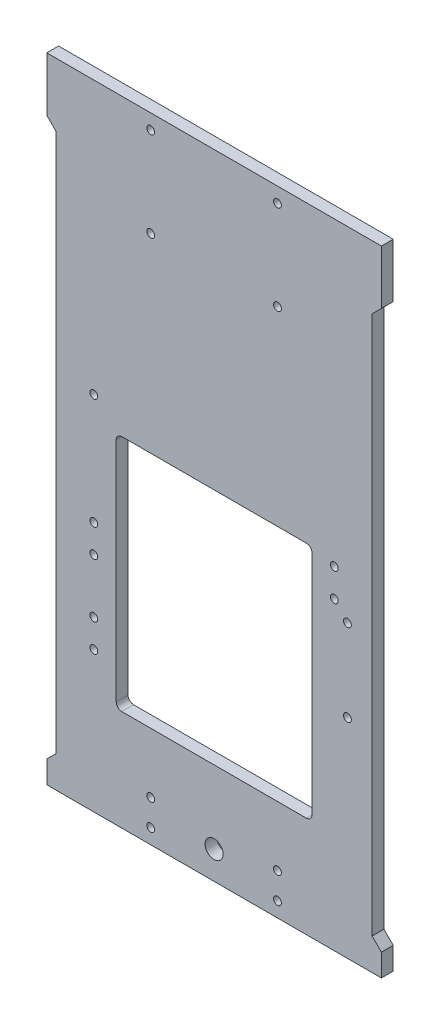
from build123d import *

# Parameters (mm, degrees)
BOSS_EXTRUDE1_DEPTH = 6.35
CUT_EXTRUDE1_DEPTH  = 7.35
SKETCH3_R           = 2.1
CUT_EXTRUDE2_DEPTH  = 7.35
SKETCH4_R           = 2.1
CUT_EXTRUDE3_DEPTH  = 7.35
SKETCH5_R           = 4.85
CUT_EXTRUDE4_DEPTH  = 7.35


with BuildPart() as part:
    # Sketch1 → Boss-Extrude1 (new body)
    with BuildSketch(Plane.XY):
        Polygon((-89.75, 0), (89.75, 0), (89.75, 12), (84.75, 17), (84.75, 306), (89.75, 311), (89.75, 340), (-89.75, 340), (-89.75, 311), (-84.75, 306), (-84.75, 17), (-89.75, 12), align=None)
    extrude(amount=BOSS_EXTRUDE1_DEPTH)

    # Sketch2 → Cut-Extrude1 (cut, through all)
    with BuildSketch(Plane.XY.offset(6.35)):
        with BuildLine():
            Line((-49.5, 181.866529721), (49.5, 181.866529721))
            ThreePointArc((49.5, 181.866529721), (51.621320344, 180.987850064), (52.5, 178.866529721))
            Line((52.5, 178.866529721), (52.5, 57.132206767))
            ThreePointArc((52.5, 57.132206767), (51.621320344, 55.010886424), (49.5, 54.132206767))
            Line((49.5, 54.132206767), (-49.5, 54.132206767))
            ThreePointArc((-49.5, 54.132206767), (-51.621320344, 55.010886424), (-52.5, 57.132206767))
            Line((-52.5, 57.132206767), (-52.5, 178.866529721))
            ThreePointArc((-52.5, 178.866529721), (-51.621320344, 180.987850064), (-49.5, 181.866529721))
        make_face()
    extrude(amount=-CUT_EXTRUDE1_DEPTH, mode=Mode.SUBTRACT)

    # Sketch3 → Cut-Extrude2 (cut, through all)
    with BuildSketch(Plane.XY.offset(6.35)):
        with Locations((-64.5, 75.499368245)):
            Circle(SKETCH3_R)
        with Locations((-64.5, 90.499368245)):
            Circle(SKETCH3_R)
        with Locations((-64.5, 134.499368243)):
            Circle(SKETCH3_R)
        with Locations((-64.5, 119.499368243)):
            Circle(SKETCH3_R)
        with Locations((-64.5, 193.905249142)):
            Circle(SKETCH3_R)
        with Locations((64.5, 163.499368242)):
            Circle(SKETCH3_R)
        with Locations((64.5, 178.499368242)):
            Circle(SKETCH3_R)
        with Locations((71.501617277, 155.85352801)):
            Circle(SKETCH3_R)
        with Locations((71.501617277, 111.85352804)):
            Circle(SKETCH3_R)
    extrude(amount=-CUT_EXTRUDE2_DEPTH, mode=Mode.SUBTRACT)

    # Sketch4 → Cut-Extrude3 (cut, through all)
    with BuildSketch(Plane.XY.offset(6.35)):
        with Locations((-34, 332)):
            Circle(SKETCH4_R)
        with Locations((34, 332)):
            Circle(SKETCH4_R)
        with Locations((34, 284)):
            Circle(SKETCH4_R)
        with Locations((-34, 284)):
            Circle(SKETCH4_R)
        with Locations((-34, 8)):
            Circle(SKETCH4_R)
        with Locations((-34, 22.001)):
            Circle(SKETCH4_R)
        with Locations((34, 22.001)):
            Circle(SKETCH4_R)
        with Locations((34, 8)):
            Circle(SKETCH4_R)
    extrude(amount=-CUT_EXTRUDE3_DEPTH, mode=Mode.SUBTRACT)

    # Sketch5 → Cut-Extrude4 (cut, through all)
    with BuildSketch(Plane.XY.offset(6.35)):
        with Locations((0, 15.0005)):
            Circle(SKETCH5_R)
    extrude(amount=-CUT_EXTRUDE4_DEPTH, mode=Mode.SUBTRACT)


solid = part.part
